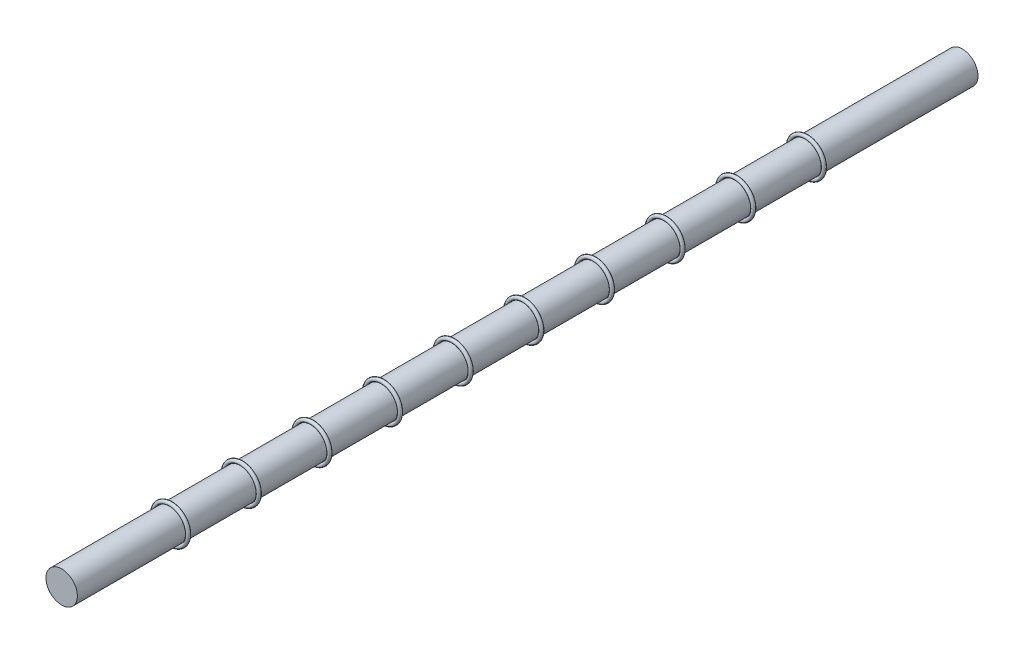
from build123d import *

# Parameters (mm, degrees)
SKETCH1_R           = 4
BOSS_EXTRUDE1_DEPTH = 229.5
SKETCH3_R           = 0.47283


with BuildPart() as part:
    # Sketch1 → Boss-Extrude1 (new body)
    with BuildSketch(Plane.XY):
        Circle(SKETCH1_R)
    extrude(amount=BOSS_EXTRUDE1_DEPTH)


with BuildPart() as body_2:
    # Sketch3 → Revolve1 (revolve)
    with BuildSketch(Plane(origin=(0, 0, 0), x_dir=(1, 0, 0), z_dir=(0, 1, 0))):
        with Locations((4.47283, -201.75)):
            Circle(SKETCH3_R)
        with Locations((4.47283, -183.75)):
            Circle(SKETCH3_R)
        with Locations((4.47283, -165.75)):
            Circle(SKETCH3_R)
        with Locations((4.47283, -147.75)):
            Circle(SKETCH3_R)
        with Locations((4.47283, -129.75)):
            Circle(SKETCH3_R)
        with Locations((4.47283, -111.75)):
            Circle(SKETCH3_R)
        with Locations((4.47283, -93.75)):
            Circle(SKETCH3_R)
        with Locations((4.47283, -75.75)):
            Circle(SKETCH3_R)
        with Locations((4.47283, -57.75)):
            Circle(SKETCH3_R)
        with Locations((4.47283, -39.75)):
            Circle(SKETCH3_R)
    revolve(axis=Axis((0, 0, 229.5), (0, 0, -1)))


solid = Compound([part.part, body_2.part])
